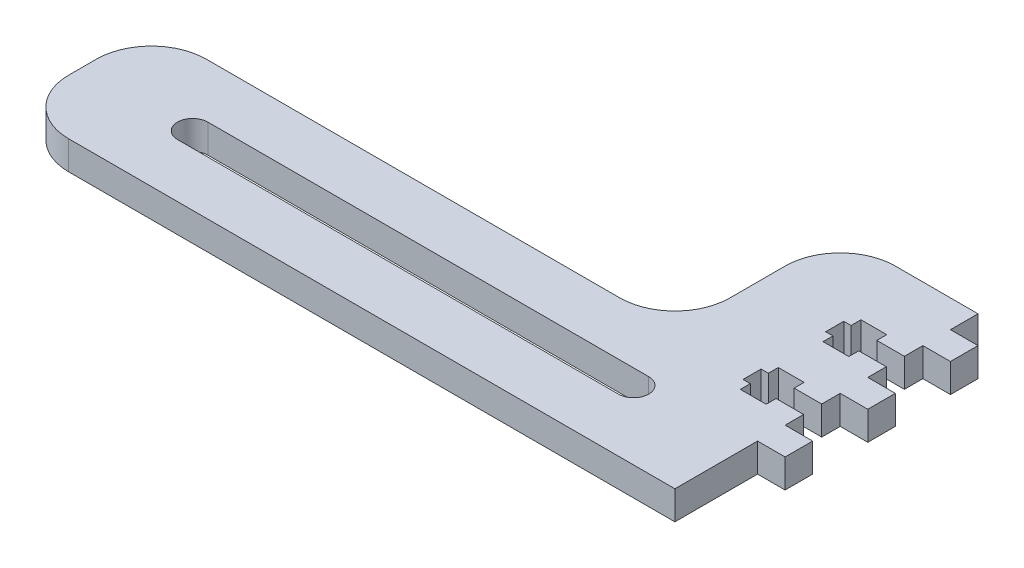
from build123d import *

# Parameters (mm, degrees)
BOSS_EXTRUDE1_DEPTH = 6.604
FILLET1_R           = 12.7
CUT_EXTRUDE1_REACH  = 8.604
CUT_EXTRUDE2_DEPTH  = 7.604
SKETCH5_W           = 6.35
SKETCH5_H           = 6.35
BOSS_EXTRUDE2_DEPTH = 6.604


with BuildPart() as part:
    # Sketch1 → Boss-Extrude1 (new body)
    with BuildSketch(Plane(origin=(0, 0, 0), x_dir=(1, 0, 0), z_dir=(0, 1, 0))):
        Polygon((-152.4, -38.1), (-152.4, -69.85), (0, -69.85), (0, 0), (-31.75, 0), (-31.75, -38.1), align=None)
    extrude(amount=BOSS_EXTRUDE1_DEPTH)

    # Fillet1
    fillet1_edges = [part.edges().sort_by_distance(p)[0] for p in [
        (-152.4, 3.302, 69.85),
        (-152.4, 3.302, 38.1),
        (-31.75, 3.302, 38.1),
        (-31.75, 3.302, 0),
    ]]
    fillet(fillet1_edges, radius=FILLET1_R)

    # Sketch2 → Cut-Extrude1 (cut, up to next)
    with BuildSketch(Plane(origin=(0, 6.604, 0), x_dir=(1, 0, 0), z_dir=(0, 1, 0)), mode=Mode.PRIVATE) as cut_extrude1_sk1:
        with BuildLine():
            Line((-127, -57.4675), (-25.4, -57.4675))
            ThreePointArc((-25.4, -57.4675), (-21.9075, -53.975), (-25.4, -50.4825))
            Line((-25.4, -50.4825), (-127, -50.4825))
            ThreePointArc((-127, -50.4825), (-130.4925, -53.975), (-127, -57.4675))
        make_face()
    cut_extrude1_tool1 = extrude(cut_extrude1_sk1.sketch, amount=-CUT_EXTRUDE1_REACH, mode=Mode.PRIVATE) & part.part
    add(cut_extrude1_tool1.solids().sort_by_distance((-76.2, 6.604, 53.975))[0], mode=Mode.SUBTRACT)

    # Sketch4 → Cut-Extrude2 (cut, through all)
    with BuildSketch(Plane(origin=(0, 6.604, 0), x_dir=(1, 0, 0), z_dir=(0, 1, 0))):
        Polygon((0, -16.9672), (-6.35, -16.9672), (-6.35, -14.6812), (-12.2936, -14.6812), (-12.2936, -16.9672), (-13.97, -16.9672), (-13.97, -21.1328), (-12.2936, -21.1328), (-12.2936, -23.4188), (-6.35, -23.4188), (-6.35, -21.1328), (0, -21.1328), align=None)
        Polygon((0, -36.0172), (-6.35, -36.0172), (-6.35, -33.7312), (-12.2936, -33.7312), (-12.2936, -36.0172), (-13.97, -36.0172), (-13.97, -40.1828), (-12.2936, -40.1828), (-12.2936, -42.4688), (-6.35, -42.4688), (-6.35, -40.1828), (0, -40.1828), align=None)
    extrude(amount=-CUT_EXTRUDE2_DEPTH, mode=Mode.SUBTRACT)

    # Sketch5 → Boss-Extrude2 (add)
    with BuildSketch(Plane(origin=(0, 6.604, 0), x_dir=(1, 0, 0), z_dir=(0, 1, 0))):
        with Locations((3.175, -9.525)):
            Rectangle(SKETCH5_W, SKETCH5_H)
        with Locations((3.175, -28.575)):
            Rectangle(SKETCH5_W, SKETCH5_H)
        with Locations((3.175, -47.625)):
            Rectangle(SKETCH5_W, SKETCH5_H)
    extrude(amount=-BOSS_EXTRUDE2_DEPTH)


solid = part.part
